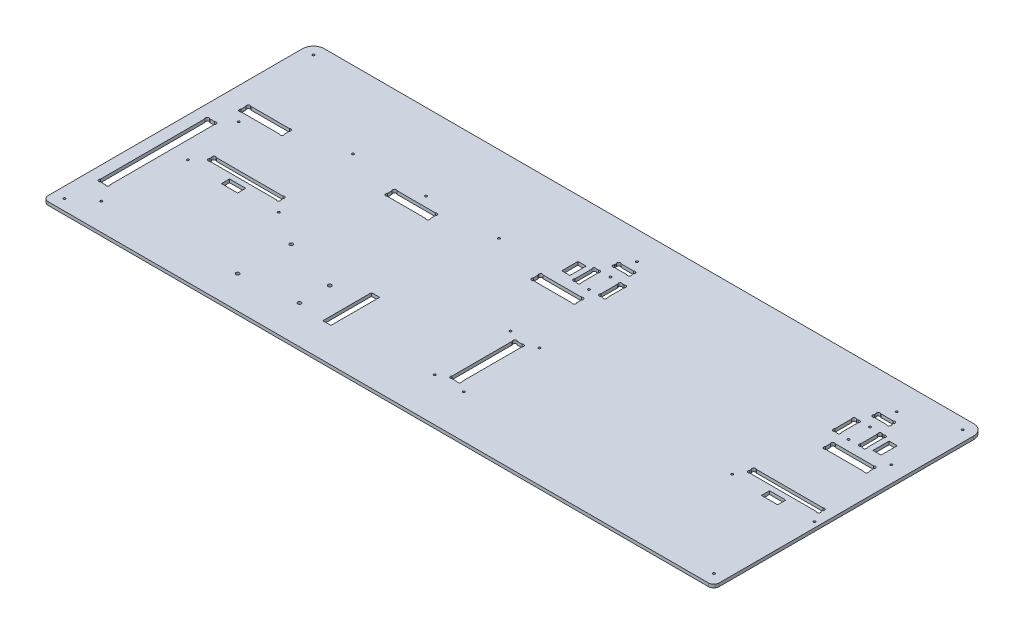
from build123d import *

# Parameters (mm, degrees)
ESQUISSE1_R             = 1
EXTRUSION1_DEPTH        = 3
ESQUISSE3_R             = 1
ENL_V_MAT_EXTRU_2_DEPTH = 4
CONG_1_R                = 5
ESQUISSE4_R             = 1
ENL_V_MAT_EXTRU_3_DEPTH = 4
ESQUISSE5_R             = 1.59
ENL_V_MAT_EXTRU_4_DEPTH = 4
ESQUISSE6_W             = 15
ESQUISSE6_H             = 7.5
ESQUISSE6_W_2           = 7.5
ESQUISSE6_H_2           = 15
ESQUISSE6_H_3           = 45
ENL_V_MAT_EXTRU_5_DEPTH = 4
ESQUISSE7_R             = 1
ENL_V_MAT_EXTRU_6_DEPTH = 4


with BuildPart() as part:
    # Esquisse1 → Extrusion1 (new body)
    with BuildSketch(Plane(origin=(0, 0, 0), x_dir=(1, 0, 0), z_dir=(0, 1, 0))):
        with BuildLine():
            Line((10, 250), (610, 250))
            ThreePointArc((610, 250), (617.071067812, 247.071067812), (620, 240))
            Line((620, 240), (620, 0))
            Line((620, 0), (0, 0))
            Line((0, 0), (0, 240))
            ThreePointArc((0, 240), (2.928932188, 247.071067812), (10, 250))
        make_face()
        with Locations(Location((539, 98, 0), (0, 0, 270))):  # turned: the seam where the file's is
            Circle(ESQUISSE1_R, mode=Mode.SUBTRACT)
        with Locations(Location((615, 98, 0), (0, 0, 270))):  # turned: the seam where the file's is
            Circle(ESQUISSE1_R, mode=Mode.SUBTRACT)
        with BuildLine():
            Line((317, 211.2627417), (317, 212.7372583))
            ThreePointArc((317, 212.7372583), (317, 215), (319.2627417, 215))
            Line((319.2627417, 215), (330.7372583, 215))
            ThreePointArc((330.7372583, 215), (333, 215), (333, 212.7372583))
            Line((333, 212.7372583), (333, 211.2627417))
            ThreePointArc((333, 211.2627417), (333, 209), (330.737258301, 209))
            Line((330.737258301, 209), (319.262741699, 209))
            ThreePointArc((319.262741699, 209), (316.999999999, 209.000000001), (317, 211.2627417))
        make_face(mode=Mode.SUBTRACT)
        with BuildLine():
            Line((312.262741699, 179.5), (313.737258301, 179.5))
            ThreePointArc((313.737258301, 179.5), (316.000000001, 179.500000001), (316, 181.762741701))
            Line((316, 181.762741701), (316, 197.237258299))
            ThreePointArc((316, 197.237258299), (316.000000001, 199.499999999), (313.737258301, 199.5))
            Line((313.737258301, 199.5), (312.262741699, 199.5))
            ThreePointArc((312.262741699, 199.5), (309.999999999, 199.499999999), (310, 197.237258299))
            Line((310, 197.237258299), (310, 181.762741701))
            ThreePointArc((310, 181.762741701), (309.999999999, 179.500000001), (312.262741699, 179.5))
        make_face(mode=Mode.SUBTRACT)
        with BuildLine():
            Line((334, 181.762741701), (334, 197.2372583))
            ThreePointArc((334, 197.2372583), (334, 199.5), (336.2627417, 199.5))
            Line((336.2627417, 199.5), (337.7372583, 199.5))
            ThreePointArc((337.7372583, 199.5), (340, 199.5), (340, 197.2372583))
            Line((340, 197.2372583), (340, 181.762741701))
            ThreePointArc((340, 181.762741701), (340.000000001, 179.500000001), (337.737258301, 179.5))
            Line((337.737258301, 179.5), (336.262741699, 179.5))
            ThreePointArc((336.262741699, 179.5), (333.999999999, 179.500000001), (334, 181.762741701))
        make_face(mode=Mode.SUBTRACT)
        with BuildLine():
            Line((552.2627417, 179.5), (553.7372583, 179.5))
            ThreePointArc((553.7372583, 179.5), (556, 179.5), (556, 181.7627417))
            Line((556, 181.7627417), (556, 197.2372583))
            ThreePointArc((556, 197.2372583), (556, 199.5), (553.7372583, 199.5))
            Line((553.7372583, 199.5), (552.2627417, 199.5))
            ThreePointArc((552.2627417, 199.5), (550, 199.5), (550, 197.2372583))
            Line((550, 197.2372583), (550, 181.7627417))
            ThreePointArc((550, 181.7627417), (550, 179.5), (552.2627417, 179.5))
        make_face(mode=Mode.SUBTRACT)
        with BuildLine():
            Line((574, 181.7627417), (574, 197.2372583))
            ThreePointArc((574, 197.2372583), (574, 199.5), (576.2627417, 199.5))
            Line((576.2627417, 199.5), (577.7372583, 199.5))
            ThreePointArc((577.7372583, 199.5), (580, 199.5), (580, 197.2372583))
            Line((580, 197.2372583), (580, 181.7627417))
            ThreePointArc((580, 181.7627417), (580, 179.5), (577.7372583, 179.5))
            Line((577.7372583, 179.5), (576.2627417, 179.5))
            ThreePointArc((576.2627417, 179.5), (574, 179.5), (574, 181.7627417))
        make_face(mode=Mode.SUBTRACT)
        with BuildLine():
            Line((559.2627417, 209), (570.7372583, 209))
            ThreePointArc((570.7372583, 209), (573, 209), (573, 211.2627417))
            Line((573, 211.2627417), (573, 212.7372583))
            ThreePointArc((573, 212.7372583), (573, 215), (570.7372583, 215))
            Line((570.7372583, 215), (559.2627417, 215))
            ThreePointArc((559.2627417, 215), (557, 215), (557, 212.7372583))
            Line((557, 212.7372583), (557, 211.2627417))
            ThreePointArc((557, 211.2627417), (557, 209), (559.2627417, 209))
        make_face(mode=Mode.SUBTRACT)
        with BuildLine():
            Line((560, 167.7372583), (560, 163.2627417))
            ThreePointArc((560, 163.2627417), (560, 161), (562.2627417, 161))
            Line((562.2627417, 161), (597.7372583, 161))
            ThreePointArc((597.7372583, 161), (600, 161), (600, 163.2627417))
            Line((600, 163.2627417), (600, 167.7372583))
            ThreePointArc((600, 167.7372583), (600, 170), (597.7372583, 170))
            Line((597.7372583, 170), (562.2627417, 170))
            ThreePointArc((562.2627417, 170), (560, 170), (560, 167.7372583))
        make_face(mode=Mode.SUBTRACT)
        with BuildLine():
            Line((292.2627417, 161), (327.7372583, 161))
            ThreePointArc((327.7372583, 161), (330, 161), (330, 163.2627417))
            Line((330, 163.2627417), (330, 167.7372583))
            ThreePointArc((330, 167.7372583), (330, 170), (327.7372583, 170))
            Line((327.7372583, 170), (292.2627417, 170))
            ThreePointArc((292.2627417, 170), (290, 170), (290, 167.7372583))
            Line((290, 167.7372583), (290, 163.2627417))
            ThreePointArc((290, 163.2627417), (290, 161), (292.2627417, 161))
        make_face(mode=Mode.SUBTRACT)
        with BuildLine():
            Line((20, 167.7372583), (20, 163.2627417))
            ThreePointArc((20, 163.2627417), (20, 161), (22.2627417, 161))
            Line((22.2627417, 161), (57.7372583, 161))
            ThreePointArc((57.7372583, 161), (60, 161), (60, 163.2627417))
            Line((60, 163.2627417), (60, 167.7372583))
            ThreePointArc((60, 167.7372583), (60, 170), (57.7372583, 170))
            Line((57.7372583, 170), (22.2627417, 170))
            ThreePointArc((22.2627417, 170), (20, 170), (20, 167.7372583))
        make_face(mode=Mode.SUBTRACT)
        with BuildLine():
            Line((155, 167.7372583), (155, 163.2627417))
            ThreePointArc((155, 163.2627417), (155, 161), (157.2627417, 161))
            Line((157.2627417, 161), (192.7372583, 161))
            ThreePointArc((192.7372583, 161), (195, 161), (195, 163.2627417))
            Line((195, 163.2627417), (195, 167.7372583))
            ThreePointArc((195, 167.7372583), (195, 170), (192.7372583, 170))
            Line((192.7372583, 170), (157.2627417, 170))
            ThreePointArc((157.2627417, 170), (155, 170), (155, 167.7372583))
        make_face(mode=Mode.SUBTRACT)
        with BuildLine():
            Line((13.2627417, 40), (17.7372583, 40))
            ThreePointArc((17.7372583, 40), (20, 40), (20, 42.2627417))
            Line((20, 42.2627417), (20, 138.7372583))
            ThreePointArc((20, 138.7372583), (20, 141), (17.7372583, 141))
            Line((17.7372583, 141), (13.2627417, 141))
            ThreePointArc((13.2627417, 141), (11, 141), (11, 138.7372583))
            Line((11, 138.7372583), (11, 42.2627417))
            ThreePointArc((11, 42.2627417), (11, 40), (13.2627417, 40))
        make_face(mode=Mode.SUBTRACT)
        with BuildLine():
            Line((337.7372583, 45), (333.2627417, 45))
            ThreePointArc((333.2627417, 45), (331, 45), (331, 47.2627417))
            Line((331, 47.2627417), (331, 102.7372583))
            ThreePointArc((331, 102.7372583), (331, 105), (333.2627417, 105))
            Line((333.2627417, 105), (337.7372583, 105))
            ThreePointArc((337.7372583, 105), (340, 105), (340, 102.7372583))
            Line((340, 102.7372583), (340, 47.2627417))
            ThreePointArc((340, 47.2627417), (340, 45), (337.7372583, 45))
        make_face(mode=Mode.SUBTRACT)
        with BuildLine():
            Line((610, 109.2627417), (610, 110.7372583))
            ThreePointArc((610, 110.7372583), (610, 113), (607.7372583, 113))
            Line((607.7372583, 113), (546.2627417, 113))
            ThreePointArc((546.2627417, 113), (544, 113), (544, 110.7372583))
            Line((544, 110.7372583), (544, 109.2627417))
            ThreePointArc((544, 109.2627417), (544, 107), (546.2627417, 107))
            Line((546.2627417, 107), (607.7372583, 107))
            ThreePointArc((607.7372583, 107), (610, 107), (610, 109.2627417))
        make_face(mode=Mode.SUBTRACT)
        with BuildLine():
            Line((108.7372583, 113), (47.2627417, 113))
            ThreePointArc((47.2627417, 113), (45, 113), (45, 110.7372583))
            Line((45, 110.7372583), (45, 109.2627417))
            ThreePointArc((45, 109.2627417), (45, 107), (47.2627417, 107))
            Line((47.2627417, 107), (108.7372583, 107))
            ThreePointArc((108.7372583, 107), (111, 107), (111, 109.2627417))
            Line((111, 109.2627417), (111, 110.7372583))
            ThreePointArc((111, 110.7372583), (111, 113), (108.7372583, 113))
        make_face(mode=Mode.SUBTRACT)
    extrude(amount=EXTRUSION1_DEPTH)

    # Esquisse3 → Enlèv. mat.-Extru.2 (cut, through all)
    with BuildSketch(Plane(origin=(0, 3, 0), x_dir=(1, 0, 0), z_dir=(0, 1, 0))):
        with Locations(Location((565, 179.5, 0), (0, 0, 270))):  # turned: the seam where the file's is
            Circle(ESQUISSE3_R)
        with Locations(Location((565, 199.5, 0), (0, 0, 270))):  # turned: the seam where the file's is
            Circle(ESQUISSE3_R)
        with Locations(Location((325, 179.5, 0), (0, 0, 270))):  # turned: the seam where the file's is
            Circle(ESQUISSE3_R)
        with Locations(Location((325, 199.5, 0), (0, 0, 270))):  # turned: the seam where the file's is
            Circle(ESQUISSE3_R)
    extrude(amount=-ENL_V_MAT_EXTRU_2_DEPTH, mode=Mode.SUBTRACT)

    # Congé1
    cong_1_edges = [part.edges().sort_by_distance(p)[0] for p in [
        (620, 1.5, 0),
        (0, 1.5, 0),
    ]]
    fillet(cong_1_edges, radius=CONG_1_R)

    # Esquisse4 → Enlèv. mat.-Extru.3 (cut, through all)
    with BuildSketch(Plane.XZ):
        with Locations(Location((10, -10, 0), (0, 0, 270))):  # turned: the seam where the file's is
            Circle(ESQUISSE4_R)
        with Locations(Location((610, -10, 0), (0, 0, 270))):  # turned: the seam where the file's is
            Circle(ESQUISSE4_R)
        with Locations(Location((610, -240, 0), (0, 0, 270))):  # turned: the seam where the file's is
            Circle(ESQUISSE4_R)
        with Locations(Location((10, -240, 0), (0, 0, 270))):  # turned: the seam where the file's is
            Circle(ESQUISSE4_R)
    extrude(amount=-ENL_V_MAT_EXTRU_3_DEPTH, mode=Mode.SUBTRACT)

    # Esquisse5 → Enlèv. mat.-Extru.4 (cut, through all)
    with BuildSketch(Plane(origin=(0, 3, 0), x_dir=(1, 0, 0), z_dir=(0, 1, 0))):
        with Locations(Location((151.27, 78.26, 0), (0, 0, 270))):  # turned: the seam where the file's is
            Circle(ESQUISSE5_R)
        with Locations(Location((150, 30, 0), (0, 0, 270))):  # turned: the seam where the file's is
            Circle(ESQUISSE5_R)
        with Locations(Location((202.07, 63.02, 0), (0, 0, 270))):  # turned: the seam where the file's is
            Circle(ESQUISSE5_R)
        with Locations(Location((202.07, 35.08, 0), (0, 0, 270))):  # turned: the seam where the file's is
            Circle(ESQUISSE5_R)
    extrude(amount=-ENL_V_MAT_EXTRU_4_DEPTH, mode=Mode.SUBTRACT)

    # Esquisse6 → Enlèv. mat.-Extru.5 (cut, through all)
    with BuildSketch(Plane(origin=(0, 3, 0), x_dir=(1, 0, 0), z_dir=(0, 1, 0))):
        with Locations((577, 98.25)):
            Rectangle(ESQUISSE6_W, ESQUISSE6_H)
        with Locations((588.75, 189.5)):
            Rectangle(ESQUISSE6_W_2, ESQUISSE6_H_2)
        with Locations((301.25, 189.5)):
            Rectangle(ESQUISSE6_W_2, ESQUISSE6_H_2)
        with Locations((230.82, 54.13)):
            Rectangle(ESQUISSE6_W_2, ESQUISSE6_H_3)
        with Locations((78, 98.25)):
            Rectangle(ESQUISSE6_W, ESQUISSE6_H)
    extrude(amount=-ENL_V_MAT_EXTRU_5_DEPTH, mode=Mode.SUBTRACT)

    # Esquisse7 → Enlèv. mat.-Extru.6 (cut, through all)
    with BuildSketch(Plane(origin=(0, 3, 0), x_dir=(1, 0, 0), z_dir=(0, 1, 0))):
        with Locations(Location((349, 110, 0), (0, 0, 270))):  # turned: the seam where the file's is
            Circle(ESQUISSE7_R)
        with Locations(Location((349, 40, 0), (0, 0, 270))):  # turned: the seam where the file's is
            Circle(ESQUISSE7_R)
        with Locations(Location((322, 110, 0), (0, 0, 270))):  # turned: the seam where the file's is
            Circle(ESQUISSE7_R)
        with Locations(Location((322, 40, 0), (0, 0, 270))):  # turned: the seam where the file's is
            Circle(ESQUISSE7_R)
        with Locations(Location((605, 179, 0), (0, 0, 270))):  # turned: the seam where the file's is
            Circle(ESQUISSE7_R)
        with Locations(Location((565, 224, 0), (0, 0, 270))):  # turned: the seam where the file's is
            Circle(ESQUISSE7_R)
        with Locations(Location((325, 224, 0), (0, 0, 270))):  # turned: the seam where the file's is
            Circle(ESQUISSE7_R)
        with Locations(Location((175, 179, 0), (0, 0, 270))):  # turned: the seam where the file's is
            Circle(ESQUISSE7_R)
        with Locations(Location((242.5, 179, 0), (0, 0, 270))):  # turned: the seam where the file's is
            Circle(ESQUISSE7_R)
        with Locations(Location((107.5, 179, 0), (0, 0, 270))):  # turned: the seam where the file's is
            Circle(ESQUISSE7_R)
        with Locations(Location((120, 98, 0), (0, 0, 270))):  # turned: the seam where the file's is
            Circle(ESQUISSE7_R)
        with Locations(Location((36, 98, 0), (0, 0, 270))):  # turned: the seam where the file's is
            Circle(ESQUISSE7_R)
        with Locations(Location((29, 152, 0), (0, 0, 270))):  # turned: the seam where the file's is
            Circle(ESQUISSE7_R)
        with Locations(Location((29, 25, 0), (0, 0, 270))):  # turned: the seam where the file's is
            Circle(ESQUISSE7_R)
    extrude(amount=-ENL_V_MAT_EXTRU_6_DEPTH, mode=Mode.SUBTRACT)


solid = part.part
